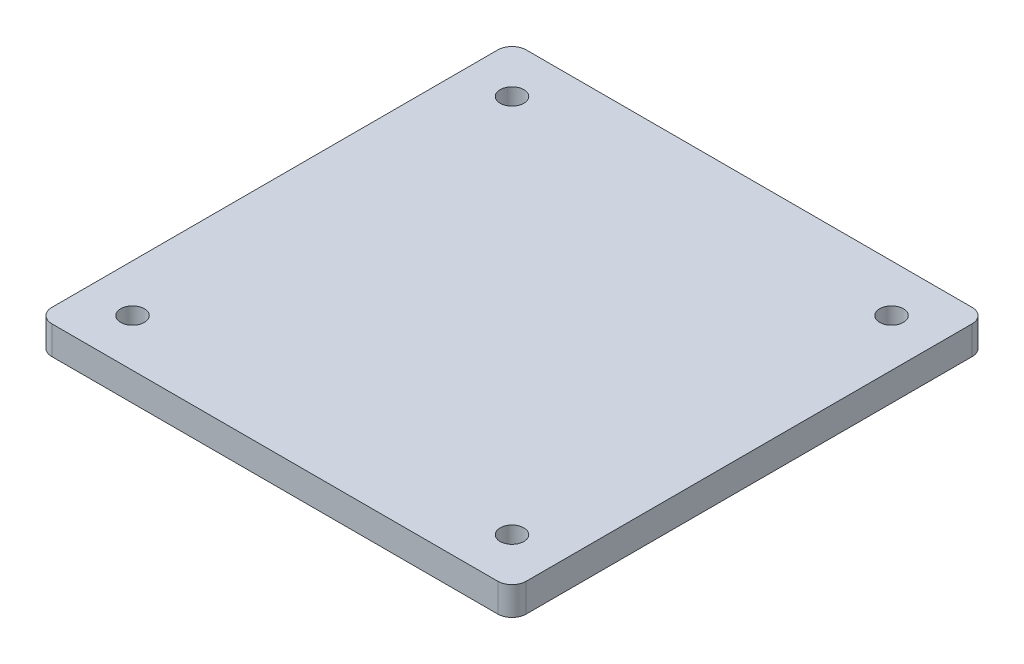
from build123d import *

# Parameters (mm, degrees)
SKETCH1_W           = 100
SKETCH1_H           = 100
SKETCH1_R           = 2.5
BOSS_EXTRUDE1_DEPTH = 6
FILLET1_R           = 3


with BuildPart() as part:
    # Sketch1 → Boss-Extrude1 (new body)
    with BuildSketch(Plane(origin=(0, 0, 0), x_dir=(1, 0, 0), z_dir=(0, 1, 0))):
        with Locations((40, -40)):
            Rectangle(SKETCH1_W, SKETCH1_H)
        Circle(SKETCH1_R, mode=Mode.SUBTRACT)
        with Locations((80, 0)):
            Circle(SKETCH1_R, mode=Mode.SUBTRACT)
        with Locations((80, -80)):
            Circle(SKETCH1_R, mode=Mode.SUBTRACT)
        with Locations((0, -80)):
            Circle(SKETCH1_R, mode=Mode.SUBTRACT)
    extrude(amount=BOSS_EXTRUDE1_DEPTH)

    # Fillet1
    fillet1_edges = [part.edges().sort_by_distance(p)[0] for p in [
        (-10, 3, -10),
        (90, 3, -10),
        (90, 3, 90),
        (-10, 3, 90),
    ]]
    fillet(fillet1_edges, radius=FILLET1_R)


solid = part.part
